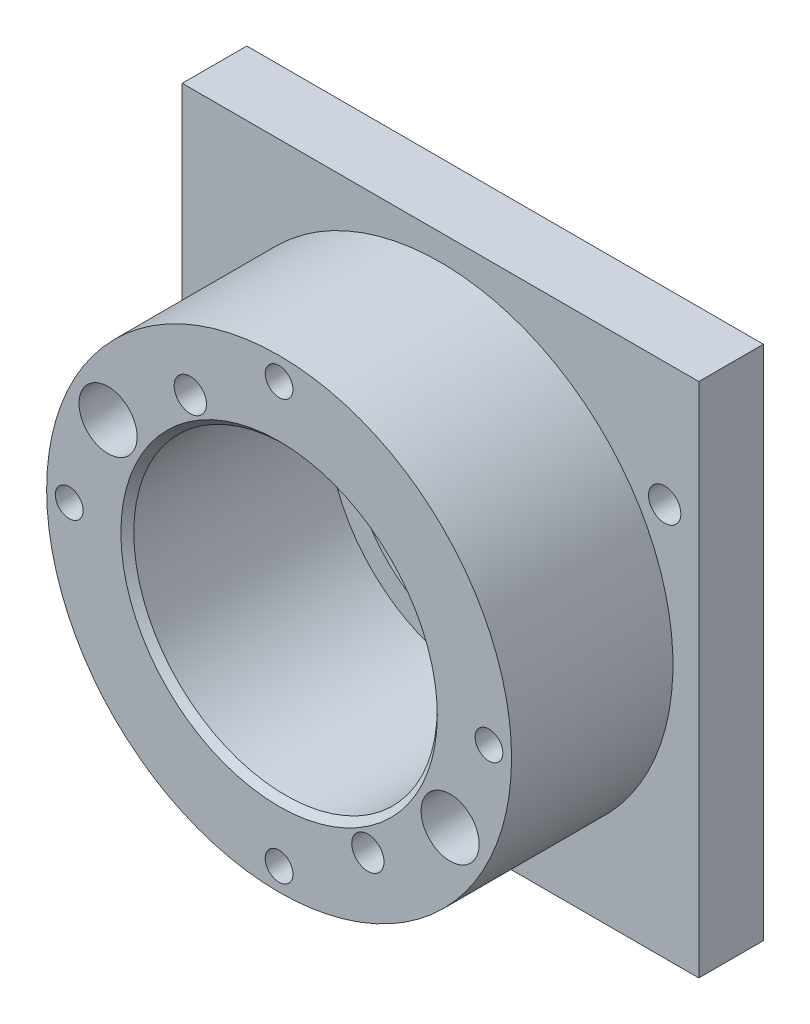
from build123d import *

# Parameters (mm, degrees)
SKIZZE1_W                                            = 80
SKIZZE1_H                                            = 80
AUFSATZ_LINEAR_AUSTRAGEN1_DEPTH                      = 10
SKIZZE16_R                                           = 20.1
SCHNITT_LINEAR_AUSTRAGEN1_DEPTH                      = 11
SKIZZE17_R                                           = 36
SKIZZE17_R_2                                         = 23.5
AUFSATZ_LINEAR_AUSTRAGEN2_DEPTH                      = 25
KREISMUSTER1_COUNT                                   = 4
FASE1_SIZE                                           = 1
F_5_0_5_DURCHMESSER_BOHRUNG1_D                       = 5
STIRNSENKUNG_F_R_M5_ZYLINDERSCHRAUBE_MIT_D           = 5
STIRNSENKUNG_F_R_M5_ZYLINDERSCHRAUBE_MIT_CBORE_D     = 9
STIRNSENKUNG_F_R_M5_ZYLINDERSCHRAUBE_MIT_CBORE_DEPTH = 7
SKIZZE39_R                                           = 23.5
SKIZZE39_R_2                                         = 20.1
SCHNITT_LINEAR_AUSTRAGEN2_DEPTH                      = 6
SKIZZE40_R                                           = 24
SKIZZE40_R_2                                         = 22
SCHNITT_LINEAR_AUSTRAGEN3_DEPTH                      = 2
AUFSATZ_LINEAR_AUSTRAGEN3_DEPTH                      = 2
SCHNITT_LINEAR_AUSTRAGEN4_DEPTH                      = 2


with BuildPart() as part:
    # Skizze1 → Aufsatz-Linear austragen1 (new body)
    with BuildSketch(Plane.XY):
        Rectangle(SKIZZE1_W, SKIZZE1_H)
    extrude(amount=AUFSATZ_LINEAR_AUSTRAGEN1_DEPTH)

    # Skizze16 → Schnitt-Linear austragen1 (cut, through all)
    with BuildSketch(Plane.XY.offset(10)):
        Circle(SKIZZE16_R)
    extrude(amount=-SCHNITT_LINEAR_AUSTRAGEN1_DEPTH, mode=Mode.SUBTRACT)

    # Skizze17 → Aufsatz-Linear austragen2 (add)
    with BuildSketch(Plane.XY.offset(10)):
        Circle(SKIZZE17_R)
        Circle(SKIZZE17_R_2, mode=Mode.SUBTRACT)
    extrude(amount=AUFSATZ_LINEAR_AUSTRAGEN2_DEPTH)

    # Skizze21 → Ø4.3 (4.3) Durchmesser Bohrung1 (revolve, cut)
    with BuildSketch(Plane(origin=(0, 32.5, 35), x_dir=(0, -1, 0), z_dir=(1, 0, 0))):
        Polygon((0, 0), (0, 16.291850331), (2.15, 15), (2.15, 0), align=None)
    f_4_3_4_3_durchmesser_bohrung1 = revolve(axis=Axis((0, 32.5, 41.35), (0, 0, -1)), mode=Mode.SUBTRACT)

    # Kreismuster1: Ø4.3 (4.3) Durchmesser Bohrung1 ×4 about axis
    kreismuster1_axis = Axis((0, 0, 0), (0, 0, 1))
    for i in range(1, KREISMUSTER1_COUNT):
        add(f_4_3_4_3_durchmesser_bohrung1.rotate(kreismuster1_axis, i * 360 / KREISMUSTER1_COUNT), mode=Mode.SUBTRACT)

    # Fase1
    fase1_edges = [part.edges().sort_by_distance(p)[0] for p in [
        (-23.5, 0, 35),
    ]]
    chamfer(fase1_edges, length=FASE1_SIZE)

    # Ø5.0 (5) Durchmesser Bohrung1 (through all)
    with Locations(Plane(origin=(0, 0, 0), x_dir=(-1, 0, 0), z_dir=(0, 0, -1))):
        with Locations((34.715275678, -20.859042034), (-13.75, -23.815698604), (13.75, 23.815698604), (-34.715275678, 20.859042034)):
            Hole(F_5_0_5_DURCHMESSER_BOHRUNG1_D / 2)

    # Stirnsenkung für M5 Zylinderschraube mit Innensechskant1 (through all)
    with Locations(Plane.XY.offset(35)):
        with Locations((-26.488427786, 14.084146884), (26.488427786, -14.084146884)):
            CounterBoreHole(STIRNSENKUNG_F_R_M5_ZYLINDERSCHRAUBE_MIT_D / 2, STIRNSENKUNG_F_R_M5_ZYLINDERSCHRAUBE_MIT_CBORE_D / 2, STIRNSENKUNG_F_R_M5_ZYLINDERSCHRAUBE_MIT_CBORE_DEPTH)

    # Skizze39 → Schnitt-Linear austragen2 (cut)
    with BuildSketch(Plane.XY.offset(10)):
        Circle(SKIZZE39_R)
        Circle(SKIZZE39_R_2, mode=Mode.SUBTRACT)
    extrude(amount=-SCHNITT_LINEAR_AUSTRAGEN2_DEPTH, mode=Mode.SUBTRACT)

    # Skizze40 → Schnitt-Linear austragen3 (cut)
    with BuildSketch(Plane(origin=(0, 0, 0), x_dir=(-1, 0, 0), z_dir=(0, 0, -1))):
        Circle(SKIZZE40_R)
        Circle(SKIZZE40_R_2, mode=Mode.SUBTRACT)
    extrude(amount=-SCHNITT_LINEAR_AUSTRAGEN3_DEPTH, mode=Mode.SUBTRACT)

    # Skizze41 → Aufsatz-Linear austragen3 (add)
    with BuildSketch(Plane(origin=(0, 0, 2), x_dir=(-1, 0, 0), z_dir=(0, 0, -1))):
        with BuildLine():
            Line((21.16903947, -8.992508512), (22.25162445, -8.992508512))
            ThreePointArc((22.25162445, -8.992508512), (24.003029137, 0.007491459), (22.251624746, 9.007491488))
            Line((22.251624746, 9.007491488), (21.169039781, 9.007491488))
            ThreePointArc((21.169039781, 9.007491488), (23.003029137, 0.007491456), (21.16903947, -8.992508512))
        make_face()
    extrude(amount=AUFSATZ_LINEAR_AUSTRAGEN3_DEPTH)

    # Skizze42 → Schnitt-Linear austragen4 (cut)
    with BuildSketch(Plane(origin=(0, 0, 0), x_dir=(-1, 0, 0), z_dir=(0, 0, -1))):
        with BuildLine():
            Line((21.431430131, -8.305164585), (21.16903947, -8.992508512))
            Line((21.16903947, -8.992508512), (21.324473431, -8.992508512))
            ThreePointArc((21.324473431, -8.992508512), (22.202579979, -9.084742871), (21.788048941, -8.305164585))
            Line((21.788048941, -8.305164585), (21.431430131, -8.305164585))
        make_face()
        with BuildLine():
            Line((21.782114297, 8.319835415), (21.431430131, 8.319835415))
            Line((21.431430131, 8.319835415), (21.169039781, 9.007491488))
            Line((21.169039781, 9.007491488), (21.318665057, 9.007491488))
            ThreePointArc((21.318665057, 9.007491488), (22.196739451, 9.099274106), (21.782114297, 8.319835415))
        make_face()
    extrude(amount=-SCHNITT_LINEAR_AUSTRAGEN4_DEPTH, mode=Mode.SUBTRACT)


solid = part.part
